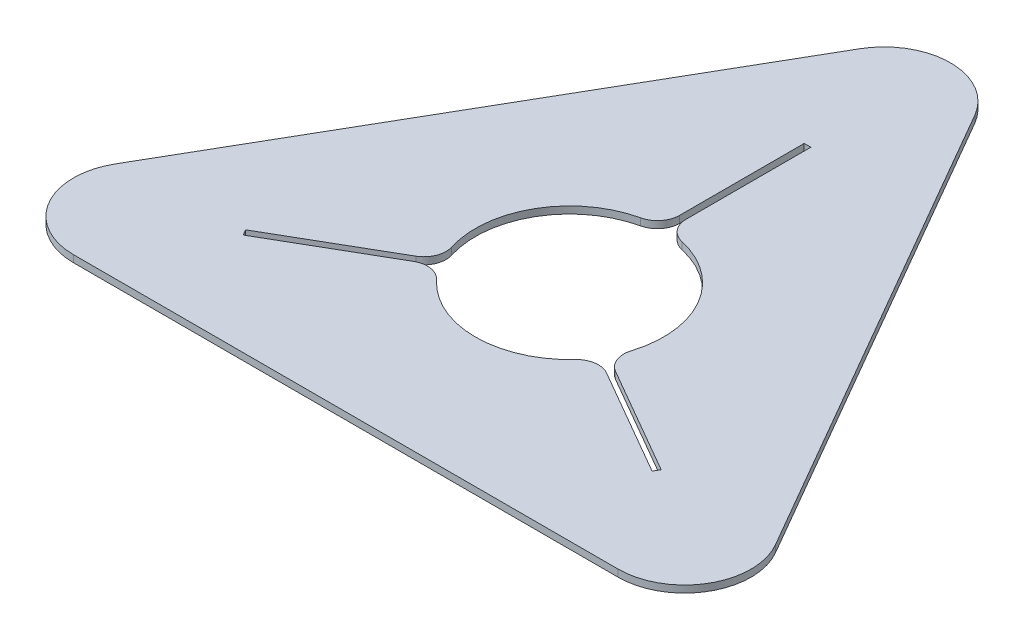
from build123d import *

# Parameters (mm, degrees)
BOSS_EXTRUDE1_DEPTH = 6.35
SKETCH2_R           = 85
CUT_EXTRUDE1_DEPTH  = 6.35
FILLET1_R           = 60
SKETCH3_W           = 6
SKETCH3_H           = 185
CUT_EXTRUDE2_DEPTH  = 6.35
FILLET2_R           = 20


with BuildPart() as part:
    # Sketch1 → Boss-Extrude1 (new body)
    with BuildSketch(Plane(origin=(0, 0, 0), x_dir=(1, 0, 0), z_dir=(0, 1, 0))):
        Polygon((0, 0), (-350, -606.217782649), (350, -606.217782649), align=None)
    extrude(amount=BOSS_EXTRUDE1_DEPTH)

    # Sketch2 → Cut-Extrude1 (cut)
    with BuildSketch(Plane(origin=(0, 6.35, 0), x_dir=(1, 0, 0), z_dir=(0, 1, 0))):
        with Locations((0, -404.145188433)):
            Circle(SKETCH2_R)
    extrude(amount=-CUT_EXTRUDE1_DEPTH, mode=Mode.SUBTRACT)

    # Fillet1
    fillet1_edges = [part.edges().sort_by_distance(p)[0] for p in [
        (350, 3.175, 606.217782649),
        (-350, 3.175, 606.217782649),
        (0, 3.175, 0),
    ]]
    fillet(fillet1_edges, radius=FILLET1_R)

    # Sketch3 → Cut-Extrude2 (cut)
    with BuildSketch(Plane(origin=(0, 6.35, 0), x_dir=(1, 0, 0), z_dir=(0, 1, 0))):
        Polygon((27.480762114, -416.547112221), (24.480762114, -421.743264644), (184.695461814, -514.243264644), (187.695461814, -509.047112221), align=None)
        with Locations((0, -281.645188433)):
            Rectangle(SKETCH3_W, SKETCH3_H)
        Polygon((-24.480762114, -421.743264644), (-27.480762114, -416.547112221), (-187.695461814, -509.047112221), (-184.695461814, -514.243264644), align=None)
    extrude(amount=-CUT_EXTRUDE2_DEPTH, mode=Mode.SUBTRACT)

    # Fillet2
    fillet2_edges = [part.edges().sort_by_distance(p)[0] for p in [
        (3, 3.175, 319.198146106),
        (-3, 3.175, 319.198146106),
        (-75.066296631, 3.175, 444.020633385),
        (-72.066296631, 3.175, 449.216785807),
        (72.066296631, 3.175, 449.216785807),
        (75.066296631, 3.175, 444.020633385),
    ]]
    fillet(fillet2_edges, radius=FILLET2_R)


solid = part.part
